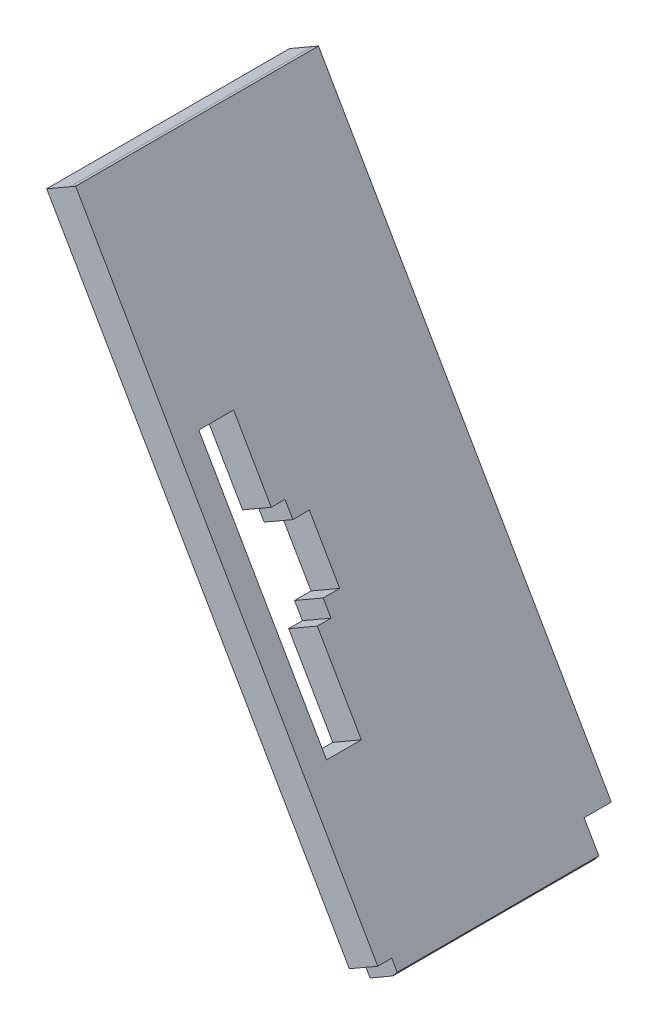
from build123d import *

# Parameters (mm, degrees)
SALIENTE_EXTRUIR1_DEPTH = 37
CORTAR_EXTRUIR1_DEPTH   = 11
CROQUIS4_W              = 5.3
CROQUIS4_H              = 39
CORTAR_EXTRUIR2_DEPTH   = 10
CORTAR_EXTRUIR3_DEPTH   = 7


with BuildPart() as part:
    # Croquis1 → Saliente-Extruir1 (new body)
    with BuildSketch(Plane.XY):
        Polygon((-99.889669891, -0.010626503), (-102.367816062, -1.441384861), (-103.432664129, -2.05617518), (-56.294122108, -83.702524956), (-52.829274, -81.702093968), (-52.153107423, -80.87251983), (-99.02316632, 0.48854437), align=None)
    extrude(amount=SALIENTE_EXTRUIR1_DEPTH)

    # Croquis2 → Cortar-Extruir1 (cut)
    with BuildSketch(Plane(origin=(-78.464848067, -45.301701153, 0), x_dir=(0, 0, 1), z_dir=(-0.866025404, -0.5, 0))):
        Polygon((4.142527364, -44.341451899), (4.142527364, -39.459427934), (0, -39.459427934), (-0.114610865, -39.459427934), (-0.114610865, -44.663143407), (4.142527364, -44.663143407), align=None)
        Polygon((34.863722121, -44.341451919), (34.863722121, -42.292638437), (37, -42.292638437), (37.495969664, -42.292638437), (37.495969664, -44.984834896), (34.863722121, -44.984834896), align=None)
    extrude(amount=-CORTAR_EXTRUIR1_DEPTH, mode=Mode.SUBTRACT)

    # Croquis4 → Cortar-Extruir2 (cut)
    with BuildSketch(Plane(origin=(-74.09577594, -42.782555705, 0), x_dir=(0, 0, 1), z_dir=(-0.866503572, -0.499170873, 0))):
        with Locations((30.774409531, 0.000869875)):
            Rectangle(CROQUIS4_W, CROQUIS4_H)
    extrude(amount=CORTAR_EXTRUIR2_DEPTH, mode=Mode.SUBTRACT)

    # Croquis5 → Cortar-Extruir3 (cut)
    with BuildSketch(Plane(origin=(-74.09577594, -42.782555705, 0), x_dir=(0, 0, 1), z_dir=(-0.866503572, -0.499170873, 0))):
        Polygon((28.224409531, 7.991554704), (26.034587607, 7.991554704), (26.034587607, 5.602236085), (23.516116629, 5.602236085), (23.516116629, -3.658890685), (26.034587607, -3.658890685), (26.034587607, -6.048209304), (28.224409531, -6.048209304), (28.726361193, -6.048209304), (28.726361193, 7.991554704), align=None)
    extrude(amount=CORTAR_EXTRUIR3_DEPTH, mode=Mode.SUBTRACT)


solid = part.part
